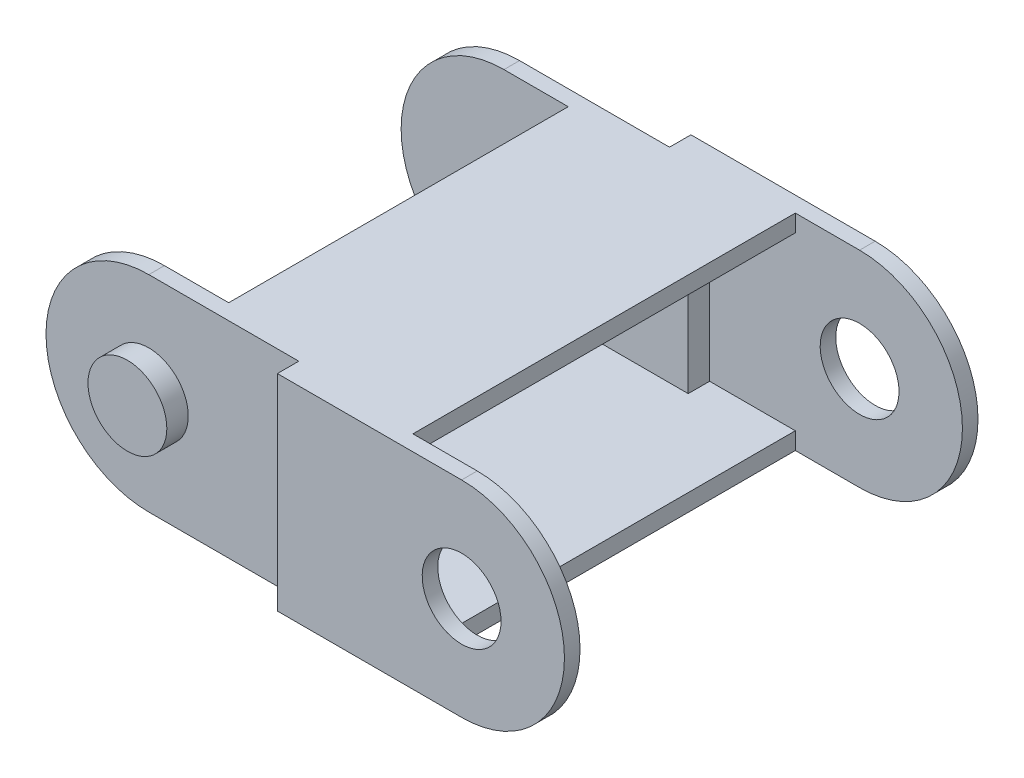
from build123d import *

# Parameters (mm, degrees)
SKETCH1_R           = 2.2999954
BOSS_EXTRUDE1_DEPTH = 12.065
SKETCH2_W           = 9.75
SKETCH2_H           = 22.312
SKETCH2_W_2         = 14.75
SKETCH2_H_2         = 1.25
SKETCH2_H_3         = 19.812
CUT_EXTRUDE1_DEPTH  = 13
SKETCH3_R           = 2.2999954
BOSS_EXTRUDE2_DEPTH = 1.25
SKETCH4_R           = 2.2999954
BOSS_EXTRUDE3_DEPTH = 1.25
SKETCH5_W           = 19.812
SKETCH5_H           = 10
CUT_EXTRUDE2_DEPTH  = 22.75
SKETCH6_W           = 1.25
SKETCH6_H           = 10
CUT_EXTRUDE3_DEPTH  = 5


with BuildPart() as part:
    # Sketch1 → Boss-Extrude1 (new body, symmetric)
    with BuildSketch(Plane(origin=(0, 0, 0), x_dir=(0, 1, 0), z_dir=(0, 0, 1))):
        with BuildLine():
            Line((-6, 0), (-6, 19.5))
            ThreePointArc((-6, 19.5), (0, 25.5), (6, 19.5))
            Line((6, 19.5), (6, 0))
            ThreePointArc((6, 0), (0, -6), (-6, 0))
        make_face()
        Circle(SKETCH1_R, mode=Mode.SUBTRACT)
    extrude(amount=BOSS_EXTRUDE1_DEPTH, both=True)

    # Sketch2 → Cut-Extrude1 (cut, through all)
    with BuildSketch(Plane.XZ.offset(6)):
        with Locations((1.125, 0)):
            Rectangle(SKETCH2_W, SKETCH2_H)
        with Locations((-18.125, 11.44)):
            Rectangle(SKETCH2_W_2, SKETCH2_H_2)
        with Locations((-18.125, -11.44)):
            Rectangle(SKETCH2_W_2, SKETCH2_H_2)
        with Locations((-20.625, 0)):
            Rectangle(SKETCH2_W, SKETCH2_H_3)
    extrude(amount=-CUT_EXTRUDE1_DEPTH, mode=Mode.SUBTRACT)

    # Sketch3 → Boss-Extrude2 (add)
    with BuildSketch(Plane.XY.offset(10.815)):
        with Locations((-19.5, 0)):
            Circle(SKETCH3_R)
    extrude(amount=BOSS_EXTRUDE2_DEPTH)

    # Sketch4 → Boss-Extrude3 (add)
    with BuildSketch(Plane(origin=(0, 0, -10.815), x_dir=(1, 0, 0), z_dir=(0, 0, -1))):
        with Locations((-19.5, 0)):
            Circle(SKETCH4_R)
    extrude(amount=BOSS_EXTRUDE3_DEPTH)

    # Sketch5 → Cut-Extrude2 (cut, through all)
    with BuildSketch(Plane(origin=(-3.75, 0, 0), x_dir=(0, 0, -1), z_dir=(1, 0, 0))):
        Rectangle(SKETCH5_W, SKETCH5_H)
    extrude(amount=-CUT_EXTRUDE2_DEPTH, mode=Mode.SUBTRACT)

    # Sketch6 → Cut-Extrude3 (cut)
    with BuildSketch(Plane(origin=(-3.75, 0, 0), x_dir=(0, 0, -1), z_dir=(1, 0, 0))):
        with Locations((-10.531, 0)):
            Rectangle(SKETCH6_W, SKETCH6_H)
        with Locations((10.531, 0)):
            Rectangle(SKETCH6_W, SKETCH6_H)
    extrude(amount=-CUT_EXTRUDE3_DEPTH, mode=Mode.SUBTRACT)


solid = part.part
